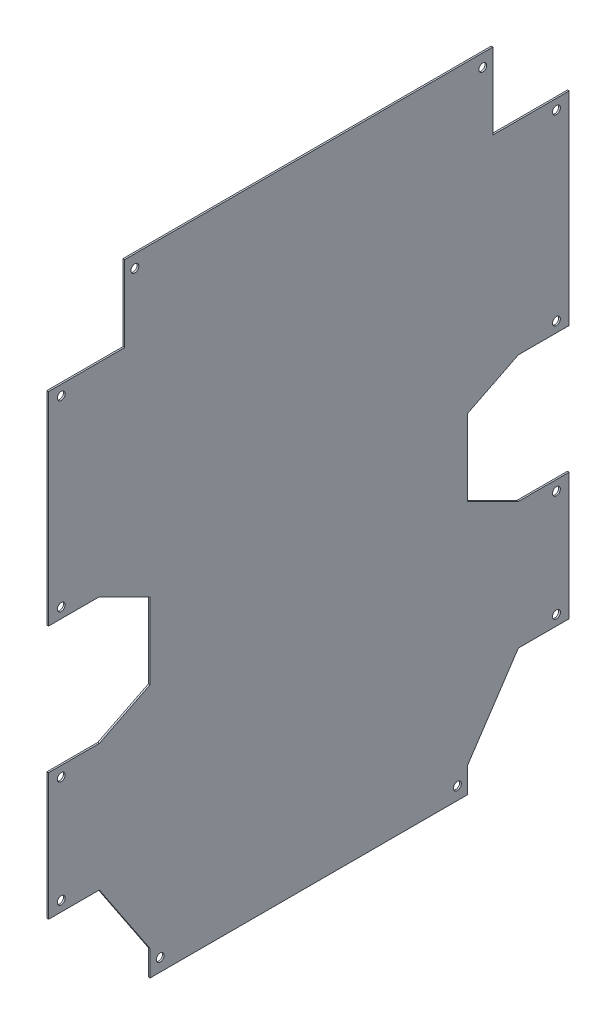
from build123d import *

# Parameters (mm, degrees)
BOSS_EXTRUDE1_DEPTH = 1.31064
SKETCH2_R           = 3.1
CUT_EXTRUDE1_DEPTH  = 10


with BuildPart() as part:
    # Sketch1 → Boss-Extrude1 (new body)
    with BuildSketch(Plane(origin=(0, 0, 0), x_dir=(0, 0, -1), z_dir=(1, 0, 0))):
        Polygon((0, 440), (0, 280), (40, 280), (80, 260), (80, 200), (40, 180), (0, 180), (0, 80), (40, 80), (80, 20), (80, 0), (330, 0), (330, 20), (370, 80), (410, 80), (410, 180), (370, 180), (330, 200), (330, 260), (370, 280), (410, 280), (410, 440), (350, 440), (350, 500), (60, 500), (60, 440), align=None)
    extrude(amount=BOSS_EXTRUDE1_DEPTH)

    # Sketch2 → Cut-Extrude1 (cut)
    with BuildSketch(Plane(origin=(1.31064, 0, 0), x_dir=(0, 0, -1), z_dir=(1, 0, 0))):
        with Locations((10, 432)):
            Circle(SKETCH2_R)
        with Locations((10, 288)):
            Circle(SKETCH2_R)
        with Locations((10, 172)):
            Circle(SKETCH2_R)
        with Locations((10, 88)):
            Circle(SKETCH2_R)
        with Locations((88, 10)):
            Circle(SKETCH2_R)
        with Locations((68, 490)):
            Circle(SKETCH2_R)
        with Locations((322, 10)):
            Circle(SKETCH2_R)
        with Locations((400, 88)):
            Circle(SKETCH2_R)
        with Locations((400, 172)):
            Circle(SKETCH2_R)
        with Locations((400, 288)):
            Circle(SKETCH2_R)
        with Locations((400, 432)):
            Circle(SKETCH2_R)
        with Locations((342, 490)):
            Circle(SKETCH2_R)
    extrude(amount=-CUT_EXTRUDE1_DEPTH, mode=Mode.SUBTRACT)


solid = part.part
